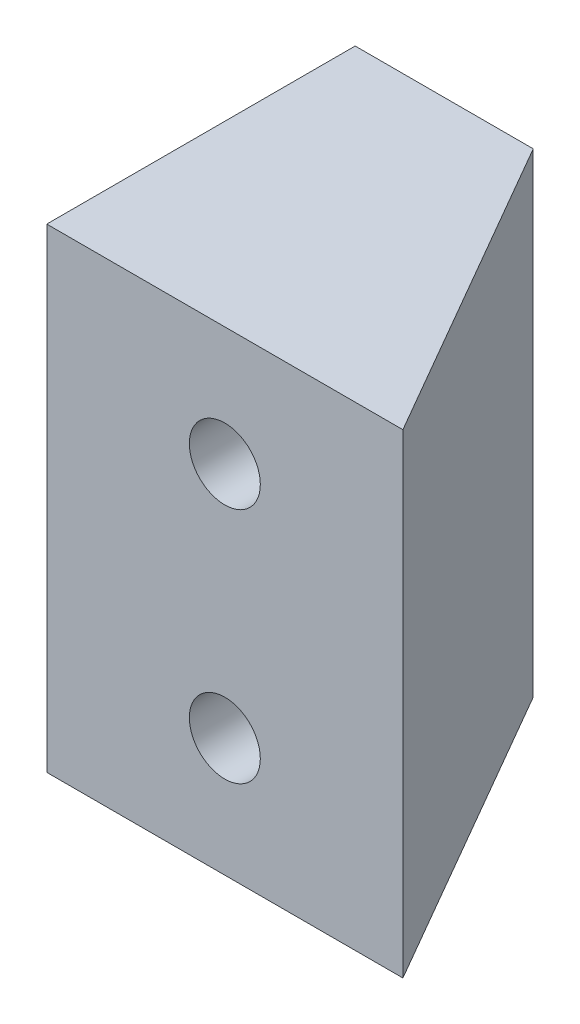
from build123d import *

# Parameters (mm, degrees)
BOSS_EXTRUDE1_DEPTH       = 25.4
F_6_CLEARANCE_HOLE1_D     = 3.7973
F_6_CLEARANCE_HOLE1_DEPTH = 12.7
F_6_CLEARANCE_HOLE1_TIP   = 1.140824014


with BuildPart() as part:
    # Sketch1 → Boss-Extrude1 (new body)
    with BuildSketch(Plane(origin=(0, 0, 0), x_dir=(1, 0, 0), z_dir=(0, 1, 0))):
        Polygon((-9.525, 10.998522628), (0, 10.998522628), (-9.525, -5.499261314), align=None)
        Polygon((9.525, -5.499261314), (0, 10.998522628), (-9.525, -5.499261314), align=None)
    extrude(amount=BOSS_EXTRUDE1_DEPTH)

    # #6 Clearance Hole1
    with Locations(Plane(origin=(0, 19.05, 5.499261314), x_dir=(1, 0, 0), z_dir=(0, 0, 1))):
        with Locations((0, 0), (0, -12.7)):
            Hole(F_6_CLEARANCE_HOLE1_D / 2, depth=F_6_CLEARANCE_HOLE1_DEPTH)
            with Locations((0, 0, -(F_6_CLEARANCE_HOLE1_DEPTH + F_6_CLEARANCE_HOLE1_TIP / 2))):  # 118° drill point
                Cone(0, F_6_CLEARANCE_HOLE1_D / 2, F_6_CLEARANCE_HOLE1_TIP, mode=Mode.SUBTRACT)


solid = part.part
